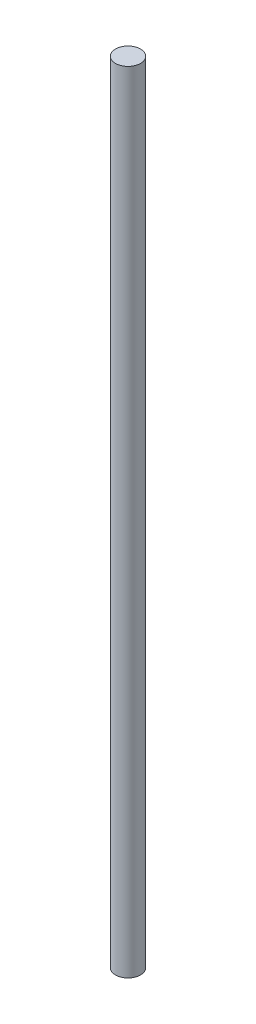
from build123d import *

# Parameters (mm, degrees)
SKETCH1_R           = 0.95
BOSS_EXTRUDE1_DEPTH = 60


with BuildPart() as part:
    # Sketch1 → Boss-Extrude1 (new body)
    with BuildSketch(Plane(origin=(0, 0, 0), x_dir=(1, 0, 0), z_dir=(0, 1, 0))):
        Circle(SKETCH1_R)
    extrude(amount=BOSS_EXTRUDE1_DEPTH)


solid = part.part
